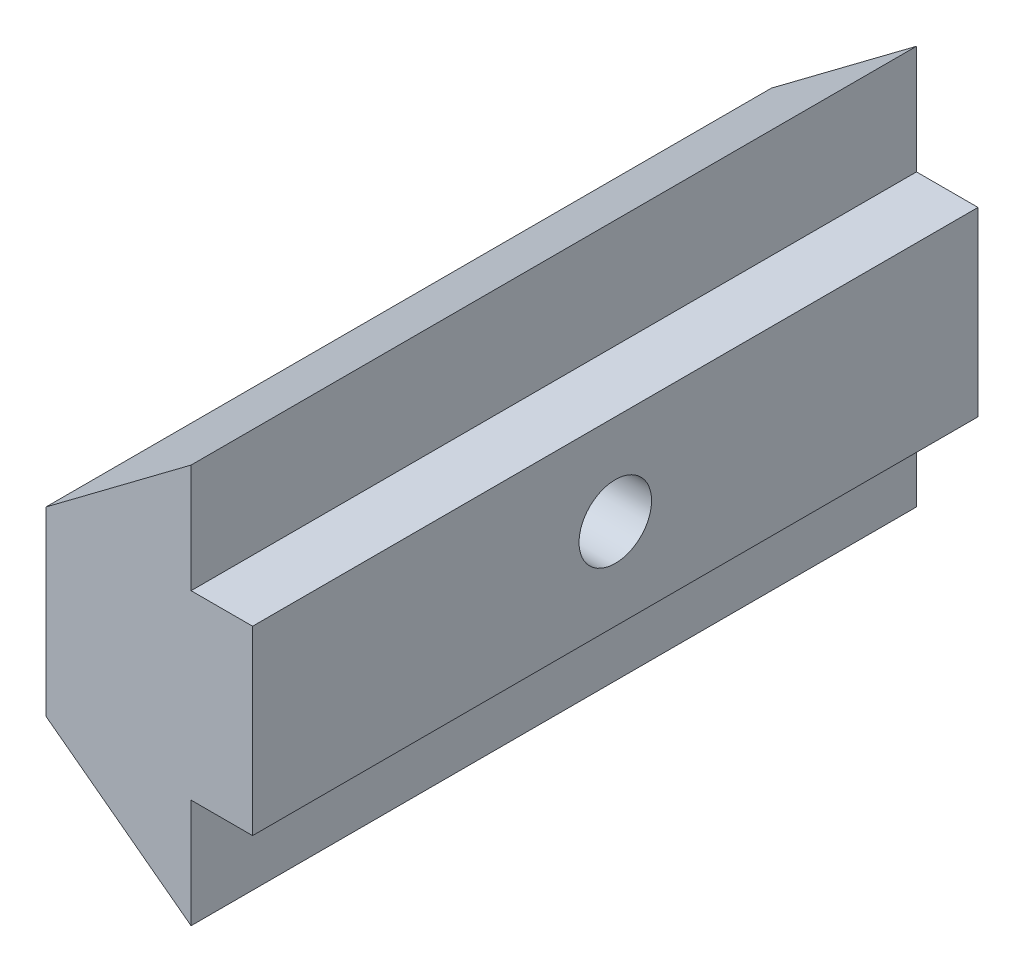
from build123d import *

# Parameters (mm, degrees)
BOSS_EXTRU_1_DEPTH      = 20
ESQUISSE1_R             = 1
ENL_V_MAT_EXTRU_1_DEPTH = 6.695841166


with BuildPart() as part:
    # ProfileRainureEsquisse → Boss.-Extru.1 (new body)
    with BuildSketch(Plane.XY):
        Polygon((0, 0), (0, 5), (4, 8), (4, 5), (5.695841166, 5), (5.695841166, 0), (4, 0), (4, -3), align=None)
    extrude(amount=BOSS_EXTRU_1_DEPTH)

    # Esquisse1 → Enlèv. mat.-Extru.1 (cut, through all)
    with BuildSketch(Plane(origin=(5.695841166, 0, 0), x_dir=(0, 0, -1), z_dir=(1, 0, 0))):
        with Locations((-10, 2.5)):
            Circle(ESQUISSE1_R)
    extrude(amount=-ENL_V_MAT_EXTRU_1_DEPTH, mode=Mode.SUBTRACT)


solid = part.part
